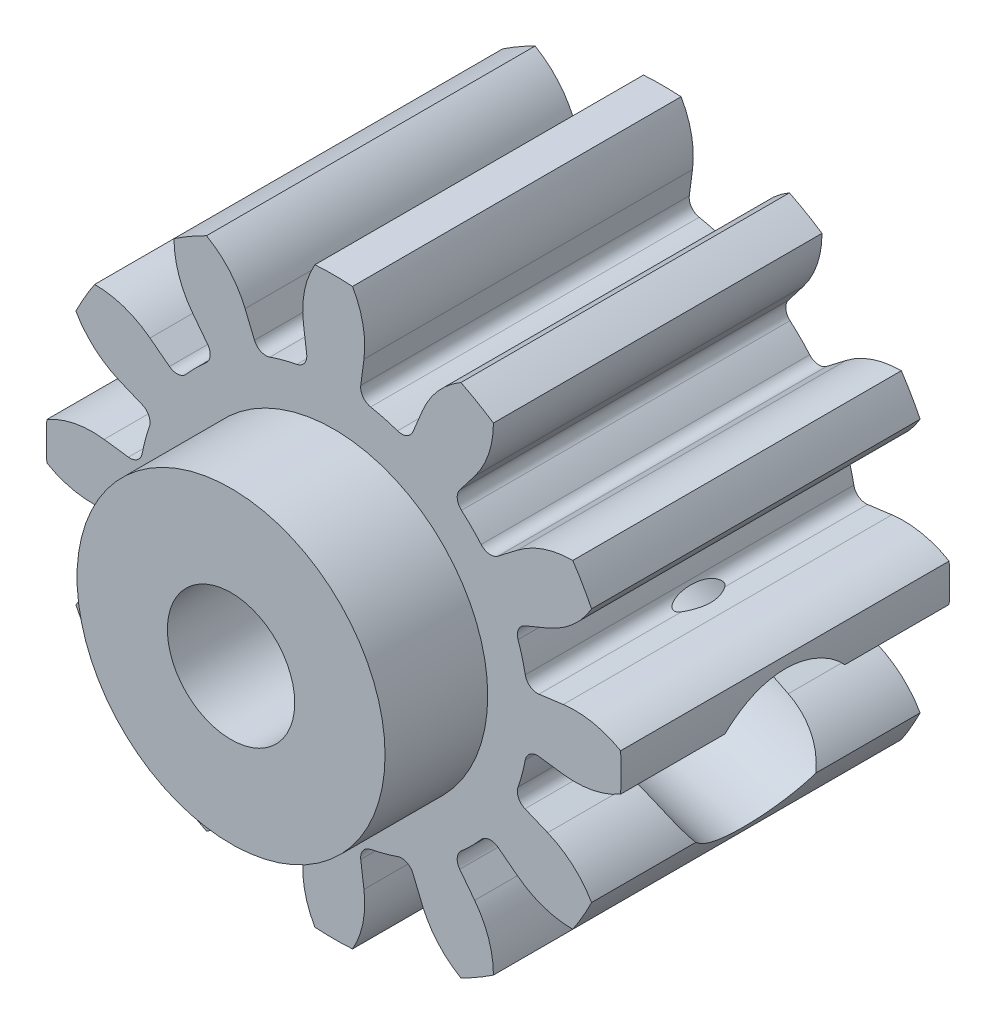
from build123d import *

# Parameters (mm, degrees)
MAINGEAR_DEPTH                     = 8
CONG_1_R                           = 0.6
R_P_TITION_CIRCULAIRE1_COUNT       = 12
CONG_1_OF_R_P_TITION_CIRCULAIRE1_R = 0.6
ESQUISSE9_R                        = 7.5
ESQUISSE9_R_2                      = 3.1
GEARBOTTOMFIX_DEPTH                = 5
ESQUISSE3_R                        = 3.1
GEARHOLE_DEPTH                     = 29.861739379
CUT_EXTRUDE2_DEPTH                 = 24.685438565
CUT_EXTRUDE2_DEPTH_BACK            = 24.685438565
SKETCH1_R                          = 1.25
SKETCH2_R                          = 4
CUT_EXTRUDE3_DEPTH                 = 28.906328701


with BuildPart() as part:
    # Esquisse1 → MainGear (new, symmetric)
    with BuildSketch(Plane.XY):
        with BuildLine():
            Line((0, 0), (9.17629535, 2.458780928))
            ThreePointArc((9.17629535, 2.458780928), (9.317460164, 1.853358059), (9.418726183, 1.239998826))
            Line((9.418726183, 1.239998826), (11.179841042, 1.471853996))
            ThreePointArc((11.179841042, 1.471853996), (12.620907812, 1.42437795), (13.970024925, 0.915643809))
            ThreePointArc((13.970024925, 0.915643809), (14, 0), (13.970024925, -0.915643809))
            ThreePointArc((13.970024925, -0.915643809), (12.620907812, -1.42437795), (11.179841042, -1.471853996))
            Line((11.179841042, -1.471853996), (9.418726183, -1.239998826))
            ThreePointArc((9.418726183, -1.239998826), (9.317460164, -1.853358059), (9.17629535, -2.458780928))
            Line((9.17629535, -2.458780928), (0, 0))
        make_face()
    maingear = extrude(amount=MAINGEAR_DEPTH, both=True)

    # Congé1
    cong_1_edges = [part.edges().sort_by_distance(p)[0] for p in [
        (9.418726183, -1.239998826, 0),
        (9.418726183, 1.239998826, 0),
    ]]
    fillet(cong_1_edges, radius=CONG_1_R)

    # Répétition circulaire1: MainGear ×12 about axis
    r_p_tition_circulaire1_axis = Axis((0, 0, 8), (0, 0, -1))
    for i in range(1, R_P_TITION_CIRCULAIRE1_COUNT):
        add(maingear.rotate(r_p_tition_circulaire1_axis, i * 360 / R_P_TITION_CIRCULAIRE1_COUNT))

    # Congé1 of Répétition circulaire1
    cong_1_of_r_p_tition_circulaire1_edges = [part.edges().sort_by_distance(p)[0] for p in [
        (7.536856733, -5.783233576, 0),
        (8.776855559, -3.635492607, 0),
        (3.635492607, -8.776855559, 0),
        (5.783233576, -7.536856733, 0),
        (-1.239998826, -9.418726183, 0),
        (1.239998826, -9.418726183, 0),
        (-5.783233576, -7.536856733, 0),
        (-3.635492607, -8.776855559, 0),
        (-8.776855559, -3.635492607, 0),
        (-7.536856733, -5.783233576, 0),
        (-9.418726183, 1.239998826, 0),
        (-9.418726183, -1.239998826, 0),
        (-7.536856733, 5.783233576, 0),
        (-8.776855559, 3.635492607, 0),
        (-3.635492607, 8.776855559, 0),
        (-5.783233576, 7.536856733, 0),
        (1.239998826, 9.418726183, 0),
        (-1.239998826, 9.418726183, 0),
        (5.783233576, 7.536856733, 0),
        (3.635492607, 8.776855559, 0),
        (8.776855559, 3.635492607, 0),
        (7.536856733, 5.783233576, 0),
    ]]
    fillet(cong_1_of_r_p_tition_circulaire1_edges, radius=CONG_1_OF_R_P_TITION_CIRCULAIRE1_R)

    # Esquisse9 → GearBottomFix (add)
    with BuildSketch(Plane.XY.offset(8)):
        Circle(ESQUISSE9_R)
        Circle(ESQUISSE9_R_2, mode=Mode.SUBTRACT)
    extrude(amount=GEARBOTTOMFIX_DEPTH)

    # Esquisse3 → GearHole (cut, through all)
    with BuildSketch(Plane.XY.offset(-8)):
        Circle(ESQUISSE3_R)
    extrude(amount=GEARHOLE_DEPTH, mode=Mode.SUBTRACT)

    # Sketch1 → Cut-Extrude2 (cut, two sides: drawn at the far end of the back side and taken through both)
    with BuildSketch(Plane(origin=(0, 0, 0), x_dir=(0, 0, -1), z_dir=(0.9659258262890681, -0.25881904510252135, 0)).offset(-CUT_EXTRUDE2_DEPTH_BACK)):
        Circle(SKETCH1_R)
    extrude(amount=CUT_EXTRUDE2_DEPTH + CUT_EXTRUDE2_DEPTH_BACK, mode=Mode.SUBTRACT)

    # Sketch2 → Cut-Extrude3 (cut, through all)
    with BuildSketch(Plane(origin=(5.289173307, -1.417229716, 0), x_dir=(0, 0, -1), z_dir=(0.9659258262890682, -0.2588190451025214, 0))):
        Circle(SKETCH2_R)
    extrude(amount=CUT_EXTRUDE3_DEPTH, mode=Mode.SUBTRACT)


solid = part.part
